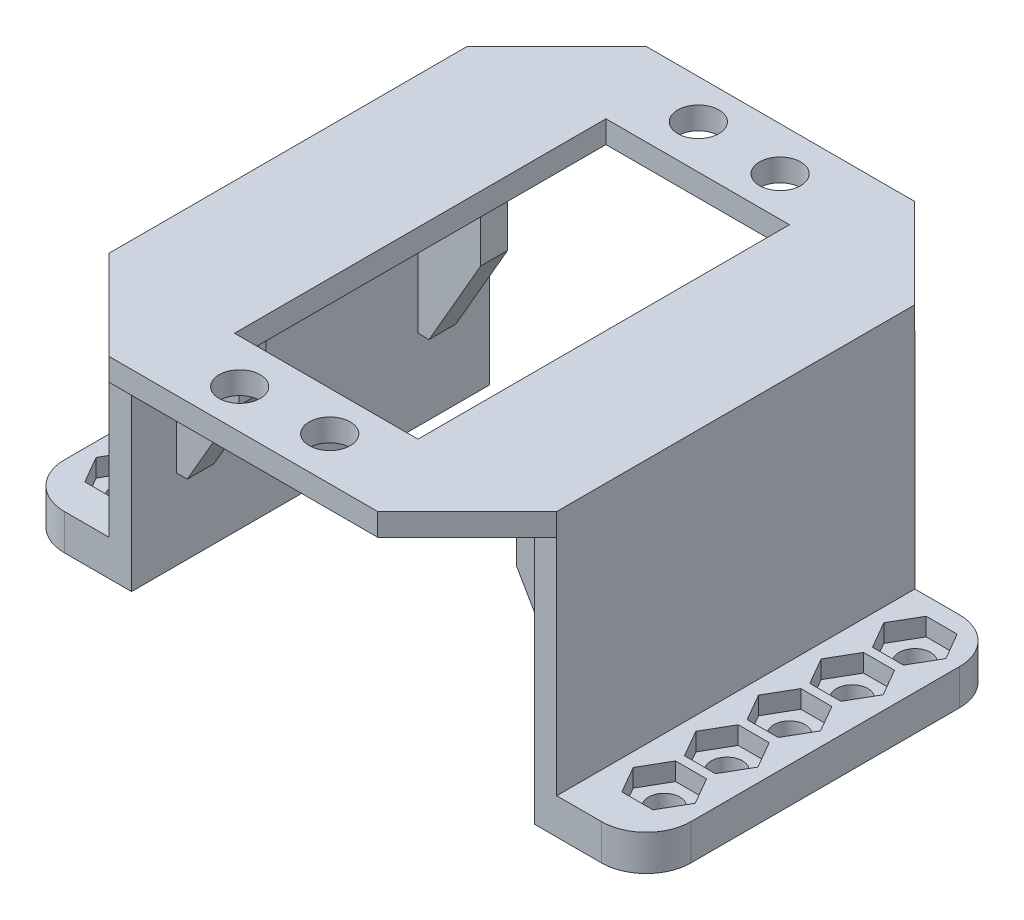
from build123d import *
from OCP.BRepFilletAPI import BRepFilletAPI_MakeChamfer

# Parameters (mm, degrees)
SKETCH1_W                 = 50
SKETCH1_H                 = 60
BOSS_EXTRUDE1_DEPTH       = 2.5
SKETCH2_W                 = 20.5
SKETCH2_H                 = 41.5
CUT_EXTRUDE1_DEPTH        = 40.131189606
CHAMFER1_SIZE             = 10
SKETCH3_W                 = 2.5
SKETCH3_H                 = 40.00831263
BOSS_EXTRUDE2_DEPTH       = 29
SKETCH4_W                 = 40.00831263
SKETCH4_H                 = 4
BOSS_EXTRUDE3_DEPTH       = 10
SKETCH5_R                 = 1.75
CUT_EXTRUDE2_DEPTH        = 54.677276384
CUT_EXTRUDE3_DEPTH        = 2
LPATTERN1_COUNT           = 5
LPATTERN1_PITCH           = 7
FILLET1_R                 = 5
SKETCH7_W                 = 7
SKETCH7_H                 = 3
BOSS_EXTRUDE4_DEPTH       = 20
CHAMFER2_SIZE             = 10
CHAMFER2_SIZE2            = 5.773502692
MIRROR1_COPY_1_SKETCH_R   = 1.75
MIRROR1_COPY_1_DEPTH      = 54.677276384
MIRROR1_COPY_2_SKETCH_R   = 1.75
MIRROR1_COPY_2_DEPTH      = 54.677276384
MIRROR1_COPY_3_SKETCH_R   = 1.75
MIRROR1_COPY_3_DEPTH      = 54.677276384
MIRROR1_COPY_4_SKETCH_R   = 1.75
MIRROR1_COPY_4_DEPTH      = 54.677276384
MIRROR1_COPY_5_DEPTH      = 2
MIRROR1_COPY_6_DEPTH      = 2
MIRROR1_COPY_7_DEPTH      = 2
MIRROR1_COPY_8_DEPTH      = 2
FILLET1_OF_MIRROR1_R      = 5
CHAMFER2_OF_MIRROR1_SIZE  = 10
CHAMFER2_OF_MIRROR1_SIZE2 = 5.773502692
SKETCH8_R                 = 2.3
CUT_EXTRUDE4_DEPTH        = 56.8323383


with BuildPart() as part:
    # Sketch1 → Boss-Extrude1 (new body)
    with BuildSketch(Plane(origin=(0, 0, 0), x_dir=(1, 0, 0), z_dir=(0, 1, 0))):
        Rectangle(SKETCH1_W, SKETCH1_H)
    extrude(amount=BOSS_EXTRUDE1_DEPTH)

    # Sketch2 → Cut-Extrude1 (cut, through all)
    with BuildSketch(Plane(origin=(0, 2.5, 0), x_dir=(1, 0, 0), z_dir=(0, 1, 0))):
        Rectangle(SKETCH2_W, SKETCH2_H)
    extrude(amount=-CUT_EXTRUDE1_DEPTH, mode=Mode.SUBTRACT)

    # Chamfer1
    chamfer1_edges = [part.edges().sort_by_distance(p)[0] for p in [
        (25, 1.25, 30),
        (-25, 1.25, 30),
        (-25, 1.25, -30),
        (25, 1.25, -30),
    ]]
    chamfer(chamfer1_edges, length=CHAMFER1_SIZE)

    # Sketch3 → Boss-Extrude2 (add)
    with BuildSketch(Plane.XZ):
        with Locations((-23.75, -0.004156315)):
            Rectangle(SKETCH3_W, SKETCH3_H)
    boss_extrude2 = extrude(amount=BOSS_EXTRUDE2_DEPTH)

    # Sketch4 → Boss-Extrude3 (add)
    with BuildSketch(Plane.ZY.offset(25)):
        with Locations((-0.004156315, -27)):
            Rectangle(SKETCH4_W, SKETCH4_H)
    boss_extrude3 = extrude(amount=BOSS_EXTRUDE3_DEPTH)

    # Sketch5 → Cut-Extrude2 (cut, through all)
    with BuildSketch(Plane(origin=(0, -25, 0), x_dir=(1, 0, 0), z_dir=(0, 1, 0))):
        with Locations(Location((-30, 15.00831263, 0), (0, 0, 270))):
            Circle(SKETCH5_R)
    cut_extrude2 = extrude(amount=-CUT_EXTRUDE2_DEPTH, mode=Mode.SUBTRACT)

    # Sketch6 → Cut-Extrude3 (cut)
    with BuildSketch(Plane(origin=(0, -25, 0), x_dir=(1, 0, 0), z_dir=(0, 1, 0))):
        Polygon((-26.535898385, 15.00831263), (-28.267949192, 18.00831263), (-31.732050808, 18.00831263), (-33.464101615, 15.00831263), (-31.732050808, 12.00831263), (-28.267949192, 12.00831263), align=None)
    cut_extrude3 = extrude(amount=-CUT_EXTRUDE3_DEPTH, mode=Mode.SUBTRACT)

    # LPattern1: Cut-Extrude2, Cut-Extrude3 ×5
    with Locations(*[(0, 0, i * LPATTERN1_PITCH) for i in range(1, LPATTERN1_COUNT)]):
        add(cut_extrude2, mode=Mode.SUBTRACT)
        add(cut_extrude3, mode=Mode.SUBTRACT)

    # Fillet1
    fillet1_edges = [part.edges().sort_by_distance(p)[0] for p in [
        (-35, -27, -20.00831263),
        (-35, -27, 20),
    ]]
    fillet(fillet1_edges, radius=FILLET1_R)

    # Sketch7 → Boss-Extrude4 (add)
    with BuildSketch(Plane.XZ):
        with Locations((-19, 13.5)):
            Rectangle(SKETCH7_W, SKETCH7_H)
        with Locations((-19, -13.50831263)):
            Rectangle(SKETCH7_W, SKETCH7_H)
    boss_extrude4 = extrude(amount=BOSS_EXTRUDE4_DEPTH)

    # Chamfer2: one chamfer whose edges measure the first distance from different faces: ONE call of the kernel's chamfer builder (chamfer() names one face for all edges)
    chamfer2_edges_1 = [part.edges().sort_by_distance(p)[0] for p in [
        (-15.5, -20, 13.5),
    ]]
    chamfer2_side_1 = [part.faces().sort_by_distance(p)[0] for p in [
        (-15.5, -10, 13.5),
    ]]
    chamfer2_edges_2 = [part.edges().sort_by_distance(p)[0] for p in [
        (-15.5, -20, -13.50831263),
    ]]
    chamfer2_side_2 = [part.faces().sort_by_distance(p)[0] for p in [
        (-15.5, -10, -13.50831263),
    ]]
    chamfer2 = BRepFilletAPI_MakeChamfer(part.part.solid().wrapped)
    for e in chamfer2_edges_1:
        chamfer2.Add(CHAMFER2_SIZE, CHAMFER2_SIZE2, e.wrapped, chamfer2_side_1[0].wrapped)  # the first distance lies on this face
    for e in chamfer2_edges_2:
        chamfer2.Add(CHAMFER2_SIZE, CHAMFER2_SIZE2, e.wrapped, chamfer2_side_2[0].wrapped)  # the first distance lies on this face
    add(Compound.cast(chamfer2.Shape()), mode=Mode.REPLACE)

    # Mirror1: Boss-Extrude2, Boss-Extrude3, Cut-Extrude2, Cut-Extrude3, Boss-Extrude4 across plane
    add(boss_extrude2.mirror(Plane(origin=(0, 0, 0), x_dir=(0, 0, 1), z_dir=(1, 0, 0))))
    add(boss_extrude3.mirror(Plane(origin=(0, 0, 0), x_dir=(0, 0, 1), z_dir=(1, 0, 0))))
    add(cut_extrude2.mirror(Plane(origin=(0, 0, 0), x_dir=(0, 0, 1), z_dir=(1, 0, 0))), mode=Mode.SUBTRACT)
    add(cut_extrude3.mirror(Plane(origin=(0, 0, 0), x_dir=(0, 0, 1), z_dir=(1, 0, 0))), mode=Mode.SUBTRACT)
    add(boss_extrude4.mirror(Plane(origin=(0, 0, 0), x_dir=(0, 0, 1), z_dir=(1, 0, 0))))

    # Mirror1 copy 1 sketch → Mirror1 copy 1 (cut, through all)
    with BuildSketch(Plane(origin=(0, -25, 7), x_dir=(-1, 0, 0), z_dir=(0, 1, 0))):
        with Locations((-30, -15.00831263)):
            Circle(MIRROR1_COPY_1_SKETCH_R)
    extrude(amount=-MIRROR1_COPY_1_DEPTH, mode=Mode.SUBTRACT)

    # Mirror1 copy 2 sketch → Mirror1 copy 2 (cut, through all)
    with BuildSketch(Plane(origin=(0, -25, 14), x_dir=(-1, 0, 0), z_dir=(0, 1, 0))):
        with Locations((-30, -15.00831263)):
            Circle(MIRROR1_COPY_2_SKETCH_R)
    extrude(amount=-MIRROR1_COPY_2_DEPTH, mode=Mode.SUBTRACT)

    # Mirror1 copy 3 sketch → Mirror1 copy 3 (cut, through all)
    with BuildSketch(Plane(origin=(0, -25, 21), x_dir=(-1, 0, 0), z_dir=(0, 1, 0))):
        with Locations((-30, -15.00831263)):
            Circle(MIRROR1_COPY_3_SKETCH_R)
    extrude(amount=-MIRROR1_COPY_3_DEPTH, mode=Mode.SUBTRACT)

    # Mirror1 copy 4 sketch → Mirror1 copy 4 (cut, through all)
    with BuildSketch(Plane(origin=(0, -25, 28), x_dir=(-1, 0, 0), z_dir=(0, 1, 0))):
        with Locations((-30, -15.00831263)):
            Circle(MIRROR1_COPY_4_SKETCH_R)
    extrude(amount=-MIRROR1_COPY_4_DEPTH, mode=Mode.SUBTRACT)

    # Mirror1 copy 5 sketch → Mirror1 copy 5 (cut)
    with BuildSketch(Plane(origin=(0, -25, 7), x_dir=(-1, 0, 0), z_dir=(0, 1, 0))):
        Polygon((-26.535898385, -15.00831263), (-28.267949192, -18.00831263), (-31.732050808, -18.00831263), (-33.464101615, -15.00831263), (-31.732050808, -12.00831263), (-28.267949192, -12.00831263), align=None)
    extrude(amount=-MIRROR1_COPY_5_DEPTH, mode=Mode.SUBTRACT)

    # Mirror1 copy 6 sketch → Mirror1 copy 6 (cut)
    with BuildSketch(Plane(origin=(0, -25, 14), x_dir=(-1, 0, 0), z_dir=(0, 1, 0))):
        Polygon((-26.535898385, -15.00831263), (-28.267949192, -18.00831263), (-31.732050808, -18.00831263), (-33.464101615, -15.00831263), (-31.732050808, -12.00831263), (-28.267949192, -12.00831263), align=None)
    extrude(amount=-MIRROR1_COPY_6_DEPTH, mode=Mode.SUBTRACT)

    # Mirror1 copy 7 sketch → Mirror1 copy 7 (cut)
    with BuildSketch(Plane(origin=(0, -25, 21), x_dir=(-1, 0, 0), z_dir=(0, 1, 0))):
        Polygon((-26.535898385, -15.00831263), (-28.267949192, -18.00831263), (-31.732050808, -18.00831263), (-33.464101615, -15.00831263), (-31.732050808, -12.00831263), (-28.267949192, -12.00831263), align=None)
    extrude(amount=-MIRROR1_COPY_7_DEPTH, mode=Mode.SUBTRACT)

    # Mirror1 copy 8 sketch → Mirror1 copy 8 (cut)
    with BuildSketch(Plane(origin=(0, -25, 28), x_dir=(-1, 0, 0), z_dir=(0, 1, 0))):
        Polygon((-26.535898385, -15.00831263), (-28.267949192, -18.00831263), (-31.732050808, -18.00831263), (-33.464101615, -15.00831263), (-31.732050808, -12.00831263), (-28.267949192, -12.00831263), align=None)
    extrude(amount=-MIRROR1_COPY_8_DEPTH, mode=Mode.SUBTRACT)

    # Fillet1 of Mirror1
    fillet1_of_mirror1_edges = [part.edges().sort_by_distance(p)[0] for p in [
        (35, -27, -20.00831263),
        (35, -27, 20),
    ]]
    fillet(fillet1_of_mirror1_edges, radius=FILLET1_OF_MIRROR1_R)

    # Chamfer2 of Mirror1: one chamfer whose edges measure the first distance from different faces: ONE call of the kernel's chamfer builder (chamfer() names one face for all edges)
    chamfer2_of_mirror1_edges_1 = [part.edges().sort_by_distance(p)[0] for p in [
        (15.5, -20, 13.5),
    ]]
    chamfer2_of_mirror1_side_1 = [part.faces().sort_by_distance(p)[0] for p in [
        (15.5, -10, 13.5),
    ]]
    chamfer2_of_mirror1_edges_2 = [part.edges().sort_by_distance(p)[0] for p in [
        (15.5, -20, -13.50831263),
    ]]
    chamfer2_of_mirror1_side_2 = [part.faces().sort_by_distance(p)[0] for p in [
        (15.5, -10, -13.50831263),
    ]]
    chamfer2_of_mirror1 = BRepFilletAPI_MakeChamfer(part.part.solid().wrapped)
    for e in chamfer2_of_mirror1_edges_1:
        chamfer2_of_mirror1.Add(CHAMFER2_OF_MIRROR1_SIZE, CHAMFER2_OF_MIRROR1_SIZE2, e.wrapped, chamfer2_of_mirror1_side_1[0].wrapped)  # the first distance lies on this face
    for e in chamfer2_of_mirror1_edges_2:
        chamfer2_of_mirror1.Add(CHAMFER2_OF_MIRROR1_SIZE, CHAMFER2_OF_MIRROR1_SIZE2, e.wrapped, chamfer2_of_mirror1_side_2[0].wrapped)  # the first distance lies on this face
    add(Compound.cast(chamfer2_of_mirror1.Shape()), mode=Mode.REPLACE)

    # Sketch8 → Cut-Extrude4 (cut, through all)
    with BuildSketch(Plane(origin=(0, 2.5, 0), x_dir=(1, 0, 0), z_dir=(0, 1, 0))):
        with Locations(Location((-4.8, 25.62, 0), (0, 0, 270))):
            Circle(SKETCH8_R)
        with Locations(Location((4.8, 25.15644981, 0), (0, 0, 270))):
            Circle(SKETCH8_R)
    cut_extrude4 = extrude(amount=-CUT_EXTRUDE4_DEPTH, mode=Mode.SUBTRACT)

    # Mirror2: Cut-Extrude4 across plane
    add(cut_extrude4.mirror(Plane.XY), mode=Mode.SUBTRACT)


solid = part.part
